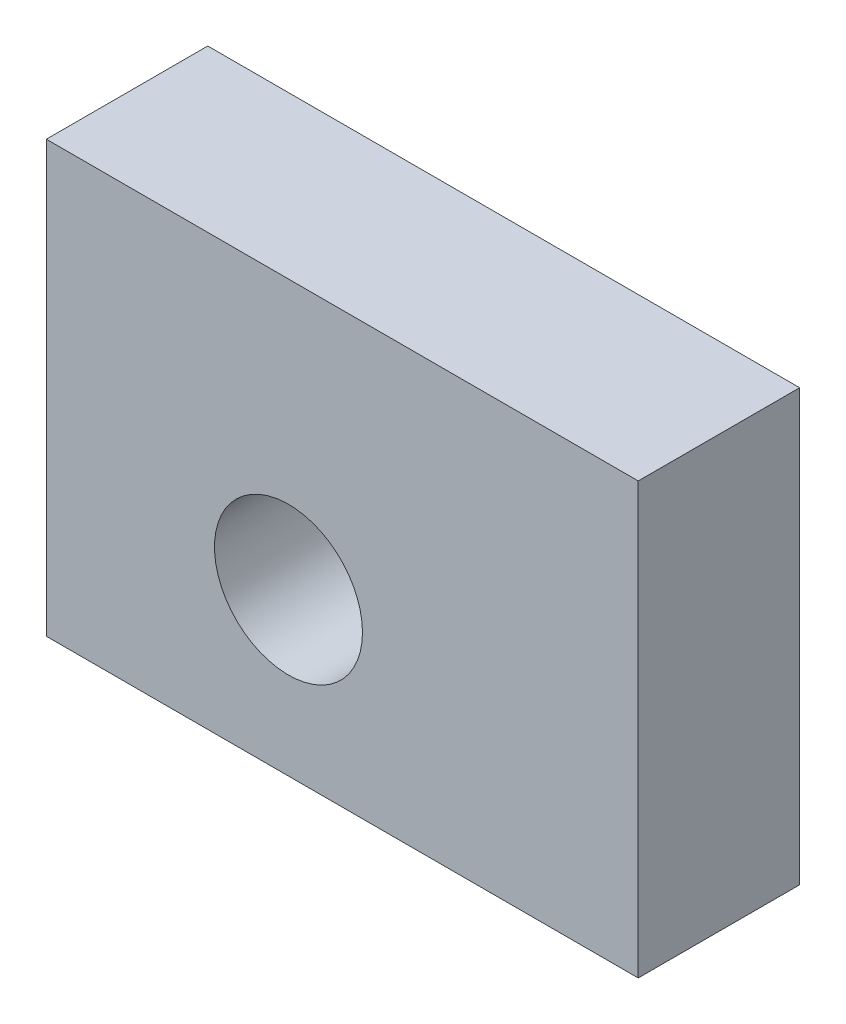
from build123d import *

# Parameters (mm, degrees)
SKETCH2_W           = 22
SKETCH2_H           = 16
SKETCH2_R           = 2.75
BOSS_EXTRUDE1_DEPTH = 6


with BuildPart() as part:
    # Sketch2 → Boss-Extrude1 (new body)
    with BuildSketch(Plane.XY):
        with Locations((11, 8)):
            Rectangle(SKETCH2_W, SKETCH2_H)
        with Locations((9, 6)):
            Circle(SKETCH2_R, mode=Mode.SUBTRACT)
    extrude(amount=BOSS_EXTRUDE1_DEPTH)


solid = part.part
